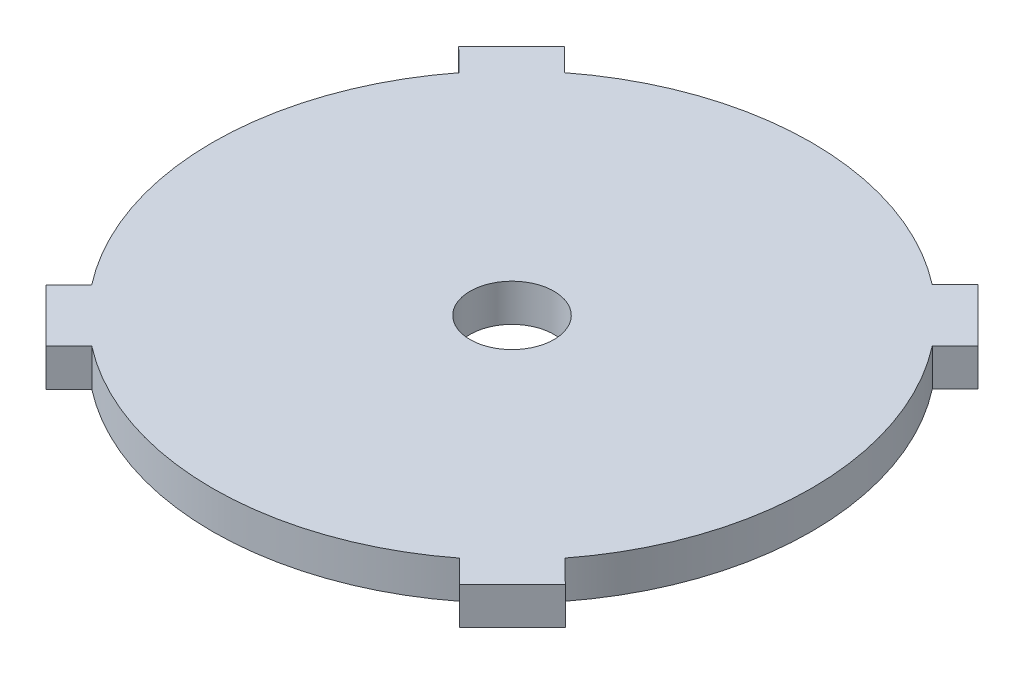
from build123d import *

# Parameters (mm, degrees)
SKETCH1_R           = 3.556
BOSS_EXTRUDE1_DEPTH = 3.175


with BuildPart() as part:
    # Sketch1 → Boss-Extrude1 (new body)
    with BuildSketch(Plane(origin=(0, 0, 0), x_dir=(1, 0, 0), z_dir=(0, 1, 0))):
        with BuildLine():
            Line((17.525786369, -21.990248683), (15.587608536, -20.05458701))
            ThreePointArc((15.587608536, -20.05458701), (0.016497958, -25.399994642), (-15.561543442, -20.074819195))
            Line((-15.561543442, -20.074819195), (-17.497205115, -22.012997028))
            Line((-17.497205115, -22.012997028), (-21.990248683, -17.525786369))
            Line((-21.990248683, -17.525786369), (-20.05458701, -15.587608536))
            ThreePointArc((-20.05458701, -15.587608536), (-25.399994642, -0.016497958), (-20.074819195, 15.561543442))
            Line((-20.074819195, 15.561543442), (-22.012997028, 17.497205115))
            Line((-22.012997028, 17.497205115), (-17.525786369, 21.990248683))
            Line((-17.525786369, 21.990248683), (-15.587608536, 20.05458701))
            ThreePointArc((-15.587608536, 20.05458701), (-0.016497958, 25.399994642), (15.561543442, 20.074819195))
            Line((15.561543442, 20.074819195), (17.497205115, 22.012997028))
            Line((17.497205115, 22.012997028), (21.990248683, 17.525786369))
            Line((21.990248683, 17.525786369), (20.05458701, 15.587608536))
            ThreePointArc((20.05458701, 15.587608536), (25.399994642, 0.016497958), (20.074819195, -15.561543442))
            Line((20.074819195, -15.561543442), (22.012997028, -17.497205115))
            Line((22.012997028, -17.497205115), (17.525786369, -21.990248683))
        make_face()
        Circle(SKETCH1_R, mode=Mode.SUBTRACT)
    extrude(amount=BOSS_EXTRUDE1_DEPTH)


solid = part.part
